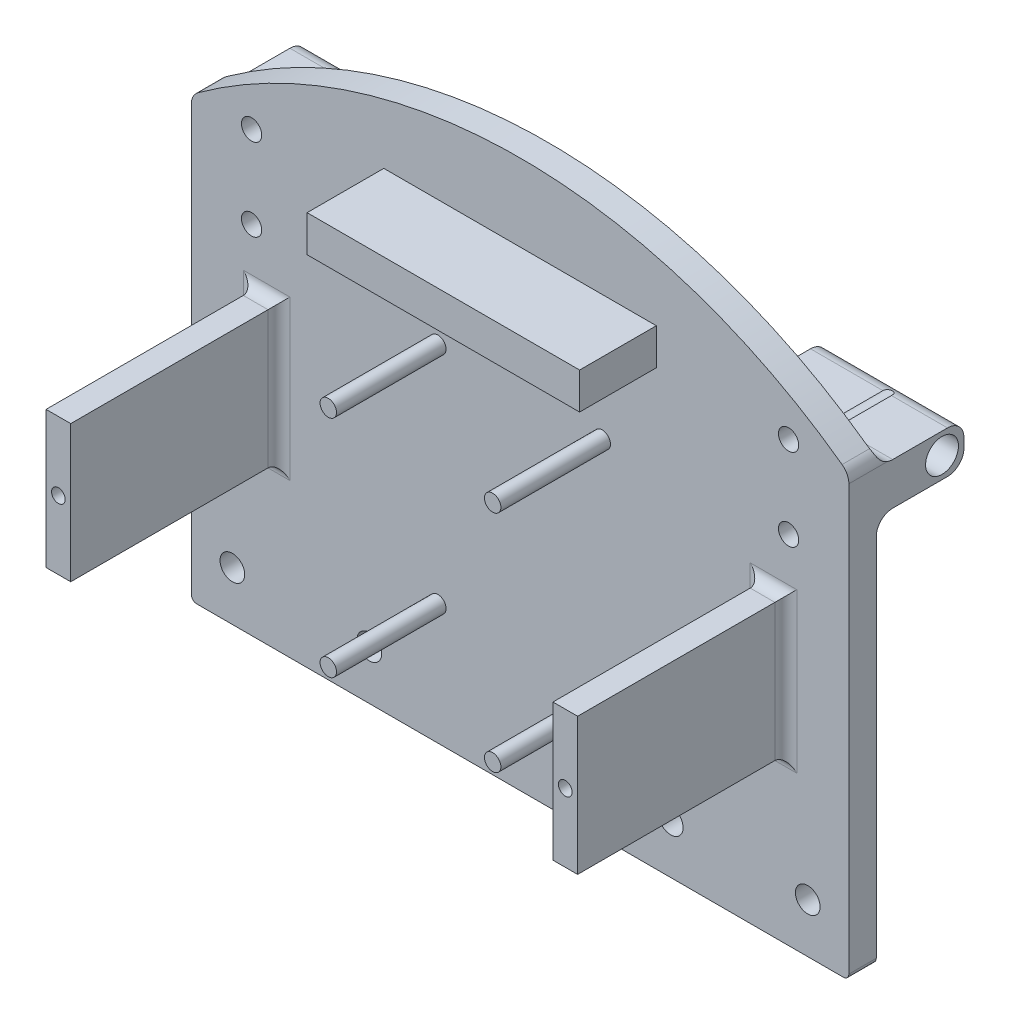
from build123d import *

# Parameters (mm, degrees)
BOSS_EXTRUDE1_DEPTH             = 2.5
SKETCH3_R                       = 2.25
CUT_EXTRUDE1_DEPTH              = 117.726175299
SKETCH4_W                       = 4.5
SKETCH4_H                       = 25
BOSS_EXTRUDE2_DEPTH             = 38
FILLET2_R                       = 2
TAP_DRILL_FOR_M3X0_5_TAP1_D     = 2.5
TAP_DRILL_FOR_M3X0_5_TAP1_DEPTH = 15
TAP_DRILL_FOR_M3X0_5_TAP1_TIP   = 0.751075774
SKETCH4_3_R                     = 1.5
BOSS_EXTRUDE3_DEPTH             = 20
SKETCH8_W                       = 21
SKETCH8_H                       = 7.693946087
SKETCH8_R                       = 3
BOSS_EXTRUDE4_DEPTH             = 25
FILLET3_R                       = 3
FILLET3_OF_MIRROR1_R            = 3
SKETCH9_W                       = 49.73363163
SKETCH9_H                       = 6.646102353
BOSS_EXTRUDE5_DEPTH             = 14
FILLET5_R                       = 3
FILLET6_R                       = 1
SKETCH10_R                      = 1.85
CUT_EXTRUDE2_DEPTH              = 123.653984982


with BuildPart() as part:
    # Sketch1 → Boss-Extrude1 (new, symmetric)
    with BuildSketch(Plane.XY):
        with BuildLine():
            Line((60, 0), (-60, 0))
            Line((-60, 0), (-60, 80))
            ThreePointArc((-60, 80), (0, 100), (60, 80))
            Line((60, 80), (60, 0))
        make_face()
    extrude(amount=BOSS_EXTRUDE1_DEPTH, both=True)

    # Sketch3 → Cut-Extrude1 (cut, through all)
    with BuildSketch(Plane.XY.offset(2.5)):
        with Locations((-52.5, 9)):
            Circle(SKETCH3_R)
        with Locations((-27.5, 9)):
            Circle(SKETCH3_R)
        with Locations((27.5, 9)):
            Circle(SKETCH3_R)
        with Locations((52.5, 9)):
            Circle(SKETCH3_R)
    extrude(amount=-CUT_EXTRUDE1_DEPTH, mode=Mode.SUBTRACT)

    # Sketch4 → Boss-Extrude2 (add)
    with BuildSketch(Plane.XY.offset(2.5)):
        with Locations((-46.25, 42.5)):
            Rectangle(SKETCH4_W, SKETCH4_H)
        with Locations((46.25, 42.5)):
            Rectangle(SKETCH4_W, SKETCH4_H)
    extrude(amount=BOSS_EXTRUDE2_DEPTH)

    # Fillet2
    fillet2_edges = [part.edges().sort_by_distance(p)[0] for p in [
        (46.25, 55, 2.5),
        (44, 42.5, 2.5),
        (46.25, 30, 2.5),
        (48.5, 42.5, 2.5),
        (-46.25, 55, 2.5),
        (-44, 42.5, 2.5),
        (-46.25, 30, 2.5),
        (-48.5, 42.5, 2.5),
    ]]
    fillet(fillet2_edges, radius=FILLET2_R)

    # Tap Drill for M3x0.5 Tap1
    with Locations(Plane.XY.offset(40.5)):
        with Locations((-46.25, 42.5), (46.25, 42.5)):
            Hole(TAP_DRILL_FOR_M3X0_5_TAP1_D / 2, depth=TAP_DRILL_FOR_M3X0_5_TAP1_DEPTH)
            with Locations((0, 0, -(TAP_DRILL_FOR_M3X0_5_TAP1_DEPTH + TAP_DRILL_FOR_M3X0_5_TAP1_TIP / 2))):  # 118° drill point
                Cone(0, TAP_DRILL_FOR_M3X0_5_TAP1_D / 2, TAP_DRILL_FOR_M3X0_5_TAP1_TIP, mode=Mode.SUBTRACT)

    # Sketch4_3 → Boss-Extrude3 (add)
    with BuildSketch(Plane.XY.offset(2.5)):
        with Locations((-15, 63)):
            Circle(SKETCH4_3_R)
        with Locations((-15, 22)):
            Circle(SKETCH4_3_R)
        with Locations((15, 22)):
            Circle(SKETCH4_3_R)
        with Locations((15, 63)):
            Circle(SKETCH4_3_R)
    extrude(amount=BOSS_EXTRUDE3_DEPTH)

    # Sketch8 → Boss-Extrude4 (add)
    with BuildSketch(Plane(origin=(60, 0, 0), x_dir=(0, 0, -1), z_dir=(1, 0, 0))):
        with Locations((8, 74.474861351)):
            Rectangle(SKETCH8_W, SKETCH8_H)
        with Locations((14.5, 74.474861351)):
            Circle(SKETCH8_R, mode=Mode.SUBTRACT)
    boss_extrude4 = extrude(amount=-BOSS_EXTRUDE4_DEPTH)

    # Fillet3
    fillet3_edges = [part.edges().sort_by_distance(p)[0] for p in [
        (47.5, 78.321834394, -18.5),
        (47.5, 78.321834394, -2.5),
        (47.5, 70.627888307, -2.5),
        (47.5, 70.627888307, -18.5),
    ]]
    fillet(fillet3_edges, radius=FILLET3_R)

    # Mirror1: Boss-Extrude4 across plane
    add(boss_extrude4.mirror(Plane(origin=(0, 0, 0), x_dir=(0, 0, 1), z_dir=(1, 0, 0))))

    # Fillet3 of Mirror1
    fillet3_of_mirror1_edges = [part.edges().sort_by_distance(p)[0] for p in [
        (-47.5, 78.321834394, -18.5),
        (-47.5, 78.321834394, -2.5),
        (-47.5, 70.627888307, -2.5),
        (-47.5, 70.627888307, -18.5),
    ]]
    fillet(fillet3_of_mirror1_edges, radius=FILLET3_OF_MIRROR1_R)

    # Sketch9 → Boss-Extrude5 (add)
    with BuildSketch(Plane.XY.offset(2.5)):
        with Locations((0, 82.579227225)):
            Rectangle(SKETCH9_W, SKETCH9_H)
    extrude(amount=BOSS_EXTRUDE5_DEPTH)

    # Fillet5
    fillet5_edges = [part.edges().sort_by_distance(p)[0] for p in [
        (60, 80, -0.153453135),
        (-60, 80, -0.153453135),
    ]]
    fillet(fillet5_edges, radius=FILLET5_R)

    # Fillet6
    fillet6_edges = [part.edges().sort_by_distance(p)[0] for p in [
        (60, 0, 0),
        (-60, 0, 0),
    ]]
    fillet(fillet6_edges, radius=FILLET6_R)

    # Sketch10 → Cut-Extrude2 (cut, through all)
    with BuildSketch(Plane.XY.offset(2.5)):
        with Locations((49, 80)):
            Circle(SKETCH10_R)
        with Locations((49, 65)):
            Circle(SKETCH10_R)
        with Locations((-49, 65)):
            Circle(SKETCH10_R)
        with Locations((-49, 80)):
            Circle(SKETCH10_R)
    extrude(amount=-CUT_EXTRUDE2_DEPTH, mode=Mode.SUBTRACT)


solid = part.part
